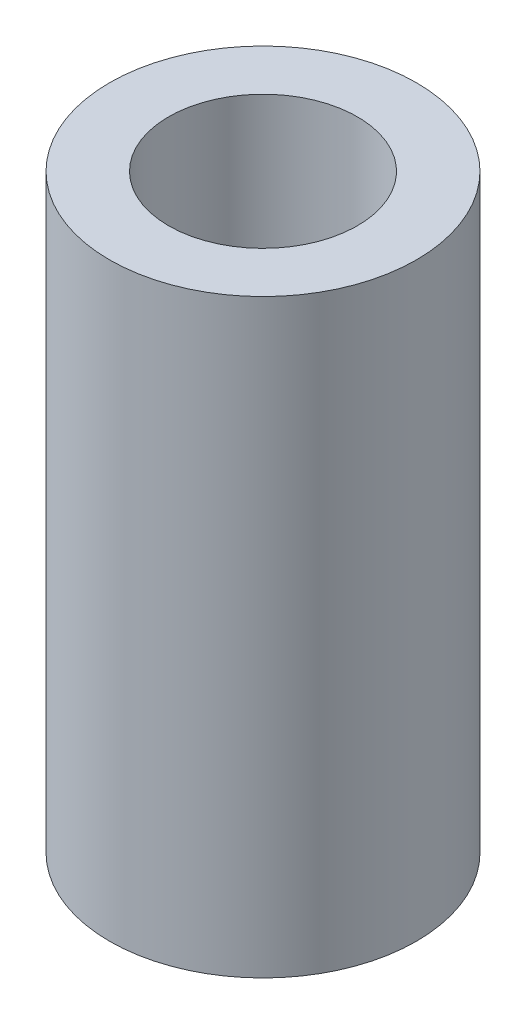
from build123d import *

# Parameters (mm, degrees)
SKETCH1_R           = 2.6
SKETCH1_R_2         = 1.6
BOSS_EXTRUDE1_DEPTH = 10


with BuildPart() as part:
    # Sketch1 → Boss-Extrude1 (new body)
    with BuildSketch(Plane(origin=(0, 0, 0), x_dir=(1, 0, 0), z_dir=(0, 1, 0))):
        Circle(SKETCH1_R)
        Circle(SKETCH1_R_2, mode=Mode.SUBTRACT)
    extrude(amount=BOSS_EXTRUDE1_DEPTH)


solid = part.part
